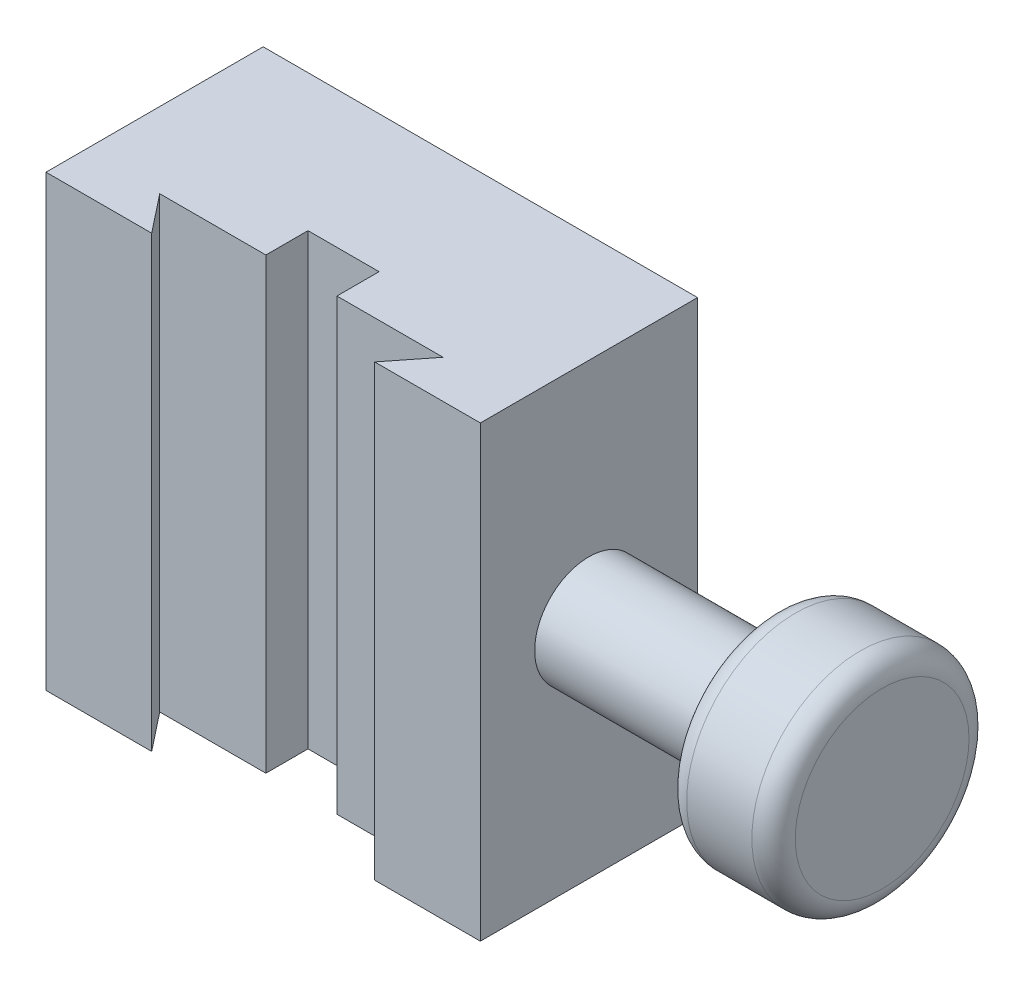
from build123d import *

# Parameters (mm, degrees)
SKETCH1_W                   = 60
SKETCH1_H                   = 62
BOSS_EXTRUDE1_DEPTH         = 30
SKETCH3_R                   = 7.5
BOSS_EXTRUDE2_DEPTH         = 25.5
SKETCH4_R                   = 15
BOSS_EXTRUDE3_DEPTH         = 15
FILLET1_R                   = 3
SKETCH1_3_W                 = 60
SKETCH1_3_H                 = 62
SKETCH1_3_R                 = 3.175
BOSS_EXTRUDE4_DEPTH         = 20
F_1_4_20_TAPPED_HOLE1_D     = 5.1054
F_1_4_20_TAPPED_HOLE1_DEPTH = 16.51
F_1_4_20_TAPPED_HOLE1_TIP   = 1.533816902
F_1_4_20_TAPPED_HOLE2_D     = 5.1054
F_1_4_20_TAPPED_HOLE2_DEPTH = 16.51
F_1_4_20_TAPPED_HOLE2_TIP   = 1.533816902
CUT_EXTRUDE1_DEPTH          = 99.560894913


with BuildPart() as part:
    # Sketch1 → Boss-Extrude1 (new body)
    with BuildSketch(Plane.XY):
        Rectangle(SKETCH1_W, SKETCH1_H)
    extrude(amount=BOSS_EXTRUDE1_DEPTH)

    # Sketch3 → Boss-Extrude2 (add)
    with BuildSketch(Plane(origin=(30, 0, 0), x_dir=(0, 0, -1), z_dir=(1, 0, 0))):
        with Locations((-15, 0)):
            Circle(SKETCH3_R)
    extrude(amount=BOSS_EXTRUDE2_DEPTH)

    # Sketch4 → Boss-Extrude3 (add)
    with BuildSketch(Plane(origin=(55.5, 0, 0), x_dir=(0, 0, -1), z_dir=(1, 0, 0))):
        with Locations((-15, 0)):
            Circle(SKETCH4_R)
    extrude(amount=BOSS_EXTRUDE3_DEPTH)

    # Fillet1
    fillet1_edges = [part.edges().sort_by_distance(p)[0] for p in [
        (55.5, 0, 30),
        (70.5, 0, 30),
    ]]
    fillet(fillet1_edges, radius=FILLET1_R)

    # Sketch1_3 → Boss-Extrude4 (add)
    with BuildSketch(Plane.XY):
        Rectangle(SKETCH1_3_W, SKETCH1_3_H)
        Circle(SKETCH1_3_R, mode=Mode.SUBTRACT)
        with Locations((25.4, 25.4)):
            Circle(SKETCH1_3_R, mode=Mode.SUBTRACT)
        with Locations((-25.4, 25.4)):
            Circle(SKETCH1_3_R, mode=Mode.SUBTRACT)
        with Locations((-25.4, -25.4)):
            Circle(SKETCH1_3_R, mode=Mode.SUBTRACT)
        with Locations((25.4, -25.4)):
            Circle(SKETCH1_3_R, mode=Mode.SUBTRACT)
        with Locations((-12.7, 12.7)):
            Circle(SKETCH1_3_R, mode=Mode.SUBTRACT)
        with Locations((12.7, 12.7)):
            Circle(SKETCH1_3_R, mode=Mode.SUBTRACT)
        with Locations((-12.7, -12.7)):
            Circle(SKETCH1_3_R, mode=Mode.SUBTRACT)
        with Locations((12.7, -12.7)):
            Circle(SKETCH1_3_R, mode=Mode.SUBTRACT)
    extrude(amount=BOSS_EXTRUDE4_DEPTH)

    # 1_4-20 Tapped Hole1
    with Locations(Plane(origin=(0, 0, 0), x_dir=(-1, 0, 0), z_dir=(0, 0, -1))):
        with Locations((-25.4, 25.4), (25.4, 25.4), (25.4, -25.4), (-25.4, -25.4)):
            Hole(F_1_4_20_TAPPED_HOLE1_D / 2, depth=F_1_4_20_TAPPED_HOLE1_DEPTH)
            with Locations((0, 0, -(F_1_4_20_TAPPED_HOLE1_DEPTH + F_1_4_20_TAPPED_HOLE1_TIP / 2))):  # 118° drill point
                Cone(0, F_1_4_20_TAPPED_HOLE1_D / 2, F_1_4_20_TAPPED_HOLE1_TIP, mode=Mode.SUBTRACT)

    # 1_4-20 Tapped Hole2
    with Locations(Plane(origin=(0, 0, 0), x_dir=(-1, 0, 0), z_dir=(0, 0, -1))):
        with Locations((-12.7, 12.7), (0, 0), (12.7, 12.7), (12.7, -12.7), (-12.7, -12.7)):
            Hole(F_1_4_20_TAPPED_HOLE2_D / 2, depth=F_1_4_20_TAPPED_HOLE2_DEPTH)
            with Locations((0, 0, -(F_1_4_20_TAPPED_HOLE2_DEPTH + F_1_4_20_TAPPED_HOLE2_TIP / 2))):  # 118° drill point
                Cone(0, F_1_4_20_TAPPED_HOLE2_D / 2, F_1_4_20_TAPPED_HOLE2_TIP, mode=Mode.SUBTRACT)

    # Sketch16 → Cut-Extrude1 (cut, through all)
    with BuildSketch(Plane.XZ.offset(31)):
        Polygon((-4.91, 24.72), (-19.57, 24.72), (-15.4, 30), (15.4, 30), (19.57, 24.72), (4.91, 24.72), (4.91, 18.9), (-4.91, 18.9), align=None)
    extrude(amount=-CUT_EXTRUDE1_DEPTH, mode=Mode.SUBTRACT)


solid = part.part
